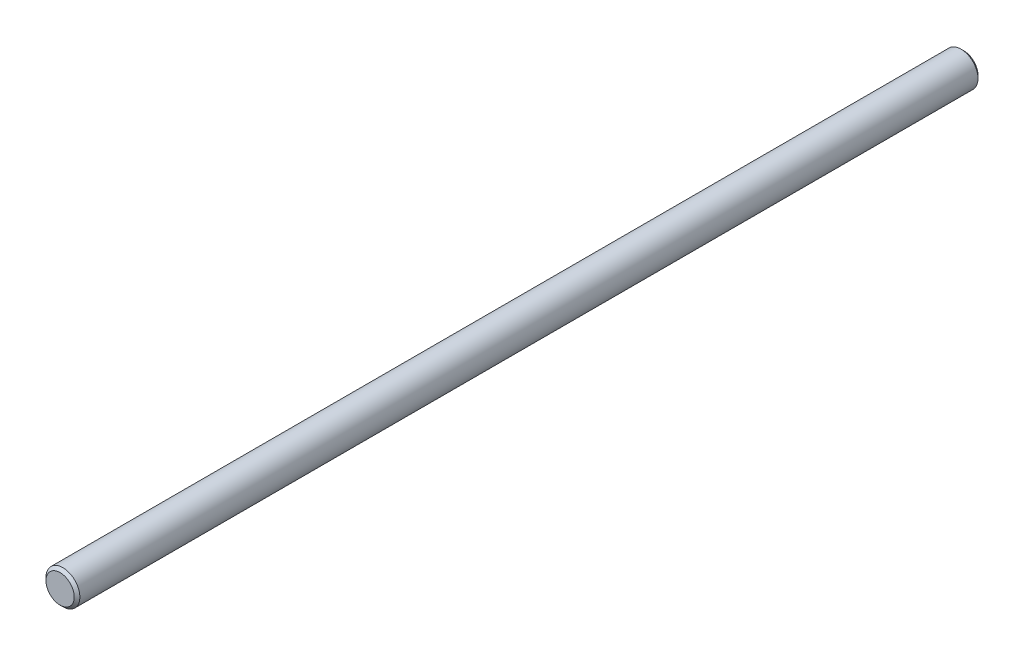
from build123d import *

# Parameters (mm, degrees)
SKETCH1_R           = 3
BOSS_EXTRUDE1_DEPTH = 160
CHAMFER1_SIZE       = 0.5
CHAMFER2_SIZE       = 0.5


with BuildPart() as part:
    # Sketch1 → Boss-Extrude1 (new body)
    with BuildSketch(Plane.XY):
        with Locations((0, 3.620771249)):
            Circle(SKETCH1_R)
    extrude(amount=BOSS_EXTRUDE1_DEPTH)

    # Chamfer1
    chamfer1_edges = [part.edges().sort_by_distance(p)[0] for p in [
        (-3, 3.620771249, 160),
    ]]
    chamfer(chamfer1_edges, length=CHAMFER1_SIZE)

    # Chamfer2
    chamfer2_edges = [part.edges().sort_by_distance(p)[0] for p in [
        (-3, 3.620771249, 0),
    ]]
    chamfer(chamfer2_edges, length=CHAMFER2_SIZE)


solid = part.part
